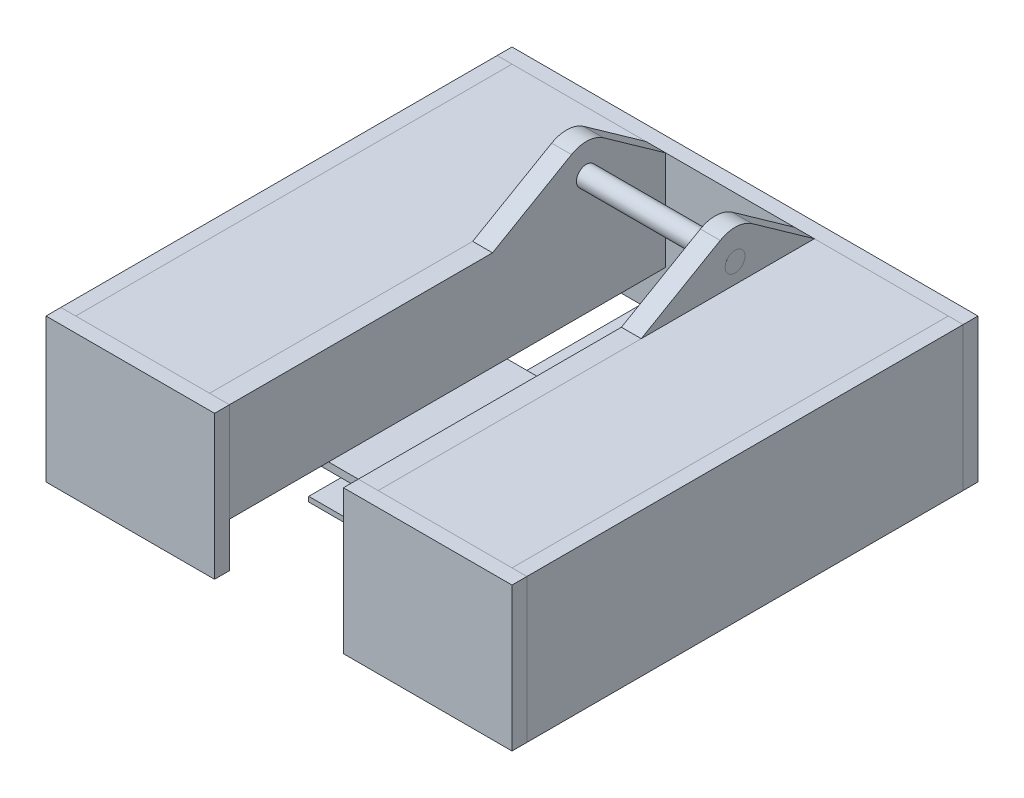
from build123d import *

# Parameters (mm, degrees)
SKETCH3_W           = 85.725
SKETCH3_H           = 109.855
SKETCH3_R           = 32.5
BOSS_EXTRUDE1_DEPTH = 6.35
SKETCH7_R           = 6.35
BOSS_EXTRUDE2_DEPTH = 12.7
SKETCH8_W           = 107.95
SKETCH8_H           = 92.075
BOSS_EXTRUDE3_DEPTH = 9.525
SKETCH10_W          = 279.4
SKETCH10_H          = 92.075
BOSS_EXTRUDE4_DEPTH = 9.525
SKETCH13_W          = 85.725
SKETCH13_H          = 279.4
BOSS_EXTRUDE7_DEPTH = 3.175
SKETCH11_W          = 298.45
SKETCH11_H          = 92.075
BOSS_EXTRUDE5_DEPTH = 9.525
SKETCH12_W          = 107.95
SKETCH12_H          = 114.3
BOSS_EXTRUDE6_DEPTH = 4.7625
BOSS_EXTRUDE8_DEPTH = 3.175
SKETCH15_R          = 6.35
BOSS_EXTRUDE9_DEPTH = 107.95


with BuildPart() as part:
    # Sketch3 → Boss-Extrude1 (new body)
    with BuildSketch(Plane(origin=(0, 53.975, 0), x_dir=(1, 0, 0), z_dir=(0, 1, 0))):
        with Locations((-96.8375, 84.7725)):
            Rectangle(SKETCH3_W, SKETCH3_H)
        with Locations((-101.6, 101.6)):
            Circle(SKETCH3_R, mode=Mode.SUBTRACT)
    extrude(amount=BOSS_EXTRUDE1_DEPTH)


with BuildPart() as body_2:
    # Mirror1: mirrored copy
    add(part.part.mirror(Plane.ZX.offset(73.025)))


with BuildPart() as body_3:
    # Mirror2: mirrored copy
    add(part.part.mirror(Plane.XY))


with BuildPart() as body_4:
    # Mirror2 2: mirrored copy
    add(body_2.part.mirror(Plane.XY))


with BuildPart() as body_5:
    # Sketch7 → Boss-Extrude2 (new body)
    with BuildSketch(Plane(origin=(-53.975, 0, 0), x_dir=(0, 0, -1), z_dir=(1, 0, 0))):
        with BuildLine():
            Line((99.927230191, 133.008920764), (139.7, 104.775))
            Line((139.7, 104.775), (139.7, 41.275))
            Line((139.7, 41.275), (-139.7, 41.275))
            Line((-139.7, 41.275), (-139.7, 104.775))
            Line((-139.7, 104.775), (28.802954744, 104.775))
            Line((28.802954744, 104.775), (79.375, 133.972783942))
            ThreePointArc((79.375, 133.972783942), (89.792430358, 136.504084793), (99.927230191, 133.008920764))
        make_face()
        with Locations((88.9, 117.475)):
            Circle(SKETCH7_R, mode=Mode.SUBTRACT)
    extrude(amount=BOSS_EXTRUDE2_DEPTH)


with BuildPart() as body_6:
    # Sketch8 → Boss-Extrude3 (new body)
    with BuildSketch(Plane.XY.offset(139.7)):
        with Locations((-95.25, 58.7375)):
            Rectangle(SKETCH8_W, SKETCH8_H)
    extrude(amount=BOSS_EXTRUDE3_DEPTH)


with BuildPart() as body_7:
    # Sketch10 → Boss-Extrude4 (new body)
    with BuildSketch(Plane.ZY.offset(139.7)):
        with Locations((0, 58.7375)):
            Rectangle(SKETCH10_W, SKETCH10_H)
    extrude(amount=BOSS_EXTRUDE4_DEPTH)


with BuildPart() as body_8:
    # Sketch13 → Boss-Extrude7 (new body)
    with BuildSketch(Plane(origin=(0, 104.775, 0), x_dir=(1, 0, 0), z_dir=(0, 1, 0))):
        with Locations((-96.8375, 0)):
            Rectangle(SKETCH13_W, SKETCH13_H)
    extrude(amount=-BOSS_EXTRUDE7_DEPTH)


with BuildPart() as body_9:
    # Mirror3: mirrored copy
    add(body_3.part.mirror(Plane(origin=(0, 0, 0), x_dir=(0, 0, 1), z_dir=(1, 0, 0))))


with BuildPart() as body_10:
    # Mirror3 2: mirrored copy
    add(body_4.part.mirror(Plane(origin=(0, 0, 0), x_dir=(0, 0, 1), z_dir=(1, 0, 0))))


with BuildPart() as body_11:
    # Mirror3 3: mirrored copy
    add(part.part.mirror(Plane(origin=(0, 0, 0), x_dir=(0, 0, 1), z_dir=(1, 0, 0))))


with BuildPart() as body_12:
    # Mirror3 4: mirrored copy
    add(body_2.part.mirror(Plane(origin=(0, 0, 0), x_dir=(0, 0, 1), z_dir=(1, 0, 0))))


with BuildPart() as body_13:
    # Mirror3 5: mirrored copy
    add(body_5.part.mirror(Plane(origin=(0, 0, 0), x_dir=(0, 0, 1), z_dir=(1, 0, 0))))


with BuildPart() as body_14:
    # Mirror3 6: mirrored copy
    add(body_7.part.mirror(Plane(origin=(0, 0, 0), x_dir=(0, 0, 1), z_dir=(1, 0, 0))))


with BuildPart() as body_15:
    # Mirror3 7: mirrored copy
    add(body_6.part.mirror(Plane(origin=(0, 0, 0), x_dir=(0, 0, 1), z_dir=(1, 0, 0))))


with BuildPart() as body_16:
    # Mirror3 8: mirrored copy
    add(body_8.part.mirror(Plane(origin=(0, 0, 0), x_dir=(0, 0, 1), z_dir=(1, 0, 0))))


with BuildPart() as body_17:
    # Sketch11 → Boss-Extrude5 (new body)
    with BuildSketch(Plane(origin=(0, 0, -139.7), x_dir=(-1, 0, 0), z_dir=(0, 0, -1))):
        with Locations((0, 58.7375)):
            Rectangle(SKETCH11_W, SKETCH11_H)
    extrude(amount=BOSS_EXTRUDE5_DEPTH)


with BuildPart() as body_18:
    # Sketch12 → Boss-Extrude6 (new body)
    with BuildSketch(Plane.XZ.offset(-41.275)):
        with Locations((0, 19.05)):
            Rectangle(SKETCH12_W, SKETCH12_H)
    extrude(amount=BOSS_EXTRUDE6_DEPTH)


with BuildPart() as body_19:
    # Sketch14 → Boss-Extrude8 (new body)
    with BuildSketch(Plane.XZ.offset(-12.7)):
        Polygon((-139.7, 33.02), (-53.975, 33.02), (-53.975, 76.2), (53.975, 76.2), (53.975, 33.02), (139.7, 33.02), (139.7, -33.02), (53.975, -33.02), (53.975, -139.7), (-53.975, -139.7), (-53.975, -33.02), (-139.7, -33.02), align=None)
    extrude(amount=-BOSS_EXTRUDE8_DEPTH)


with BuildPart() as body_20:
    # Sketch15 → Boss-Extrude9 (new body)
    with BuildSketch(Plane.ZY.offset(53.975)):
        with Locations((-88.9, 117.475)):
            Circle(SKETCH15_R)
    extrude(amount=-BOSS_EXTRUDE9_DEPTH)


solid = Compound([part.part, body_2.part, body_3.part, body_4.part, body_5.part, body_6.part, body_7.part, body_8.part, body_9.part, body_10.part, body_11.part, body_12.part, body_13.part, body_14.part, body_15.part, body_16.part, body_17.part, body_18.part, body_19.part, body_20.part])
